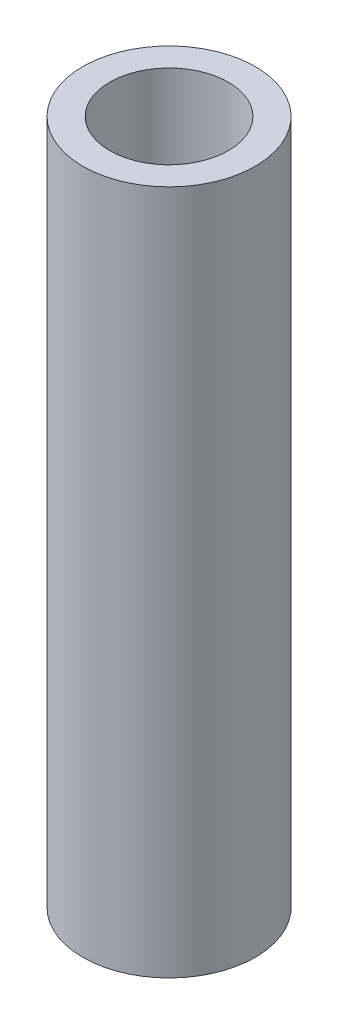
from build123d import *

# Parameters (mm, degrees)
SKETCH1_R           = 3.2
SKETCH1_R_2         = 2.2
BOSS_EXTRUDE1_DEPTH = 25.4


with BuildPart() as part:
    # Sketch1 → Boss-Extrude1 (new body)
    with BuildSketch(Plane(origin=(0, 0, 0), x_dir=(1, 0, 0), z_dir=(0, 1, 0))):
        Circle(SKETCH1_R)
        Circle(SKETCH1_R_2, mode=Mode.SUBTRACT)
    extrude(amount=BOSS_EXTRUDE1_DEPTH)


solid = part.part
